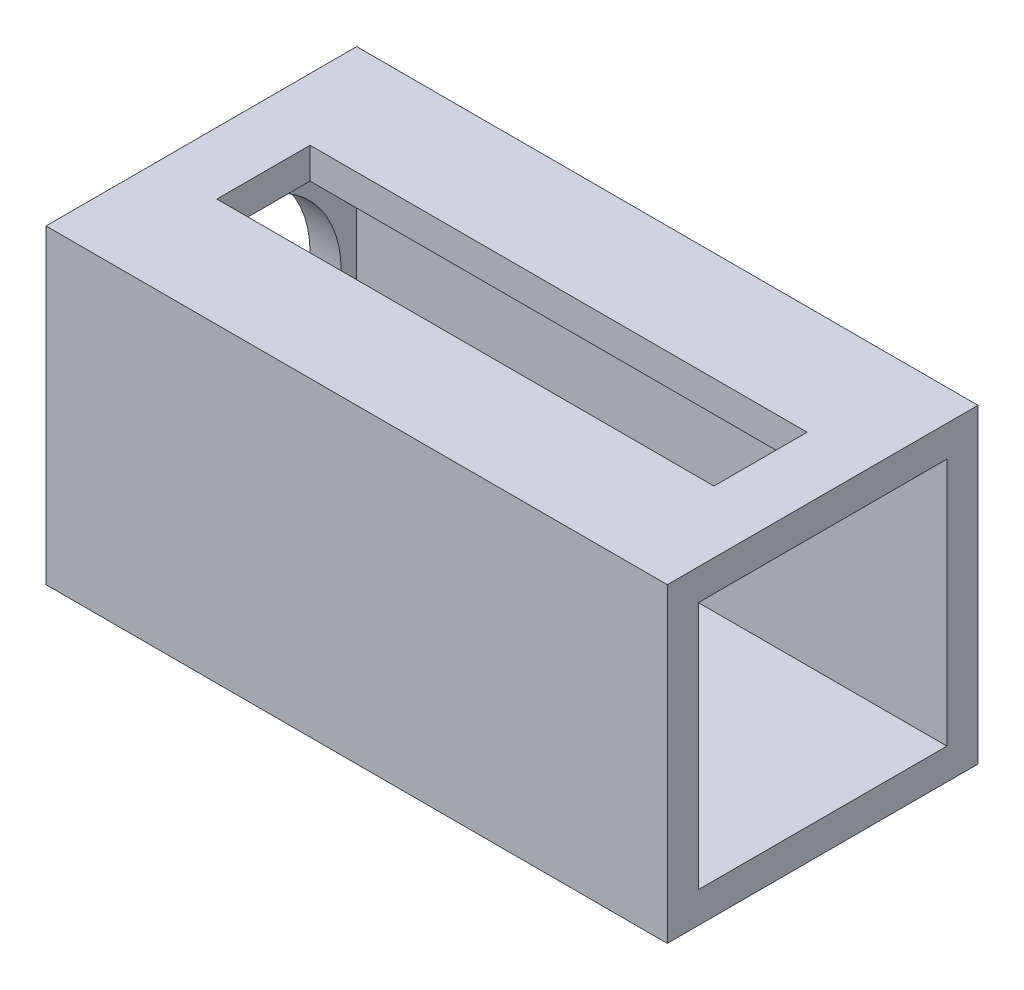
from build123d import *

# Parameters (mm, degrees)
SKETCH1_W           = 20
SKETCH1_H           = 10
BOSS_EXTRUDE1_DEPTH = 10
SHELL1_T            = -1
CUT_EXTRUDE1_REACH  = 22
SKETCH3_R           = 3.5
CUT_EXTRUDE2_REACH  = 12
SKETCH5_W           = 16
SKETCH5_H           = 3


with BuildPart() as part:
    # Sketch1 → Boss-Extrude1 (new body)
    with BuildSketch(Plane.XY):
        Rectangle(SKETCH1_W, SKETCH1_H)
    extrude(amount=BOSS_EXTRUDE1_DEPTH)

    # Shell1
    shell1_openings = [part.faces().sort_by_distance(p)[0] for p in [
        (10, 0, 5),
    ]]
    offset(amount=SHELL1_T, openings=shell1_openings, kind=Kind.INTERSECTION)

    # Sketch3 → Cut-Extrude1 (cut, up to next)
    with BuildSketch(Plane.ZY.offset(10), mode=Mode.PRIVATE) as cut_extrude1_sk1:
        with Locations((5, 0)):
            Circle(SKETCH3_R)
    cut_extrude1_tool1 = extrude(cut_extrude1_sk1.sketch, amount=-CUT_EXTRUDE1_REACH, mode=Mode.PRIVATE) & part.part
    add(cut_extrude1_tool1.solids().sort_by_distance((-10, 0, 5))[0], mode=Mode.SUBTRACT)

    # Sketch5 → Cut-Extrude2 (cut, up to next)
    with BuildSketch(Plane(origin=(0, 5, 0), x_dir=(1, 0, 0), z_dir=(0, 1, 0)), mode=Mode.PRIVATE) as cut_extrude2_sk1:
        with Locations((0, -5)):
            Rectangle(SKETCH5_W, SKETCH5_H)
    cut_extrude2_tool1 = extrude(cut_extrude2_sk1.sketch, amount=-CUT_EXTRUDE2_REACH, mode=Mode.PRIVATE) & part.part
    add(cut_extrude2_tool1.solids().sort_by_distance((0, 5, 5))[0], mode=Mode.SUBTRACT)


solid = part.part
